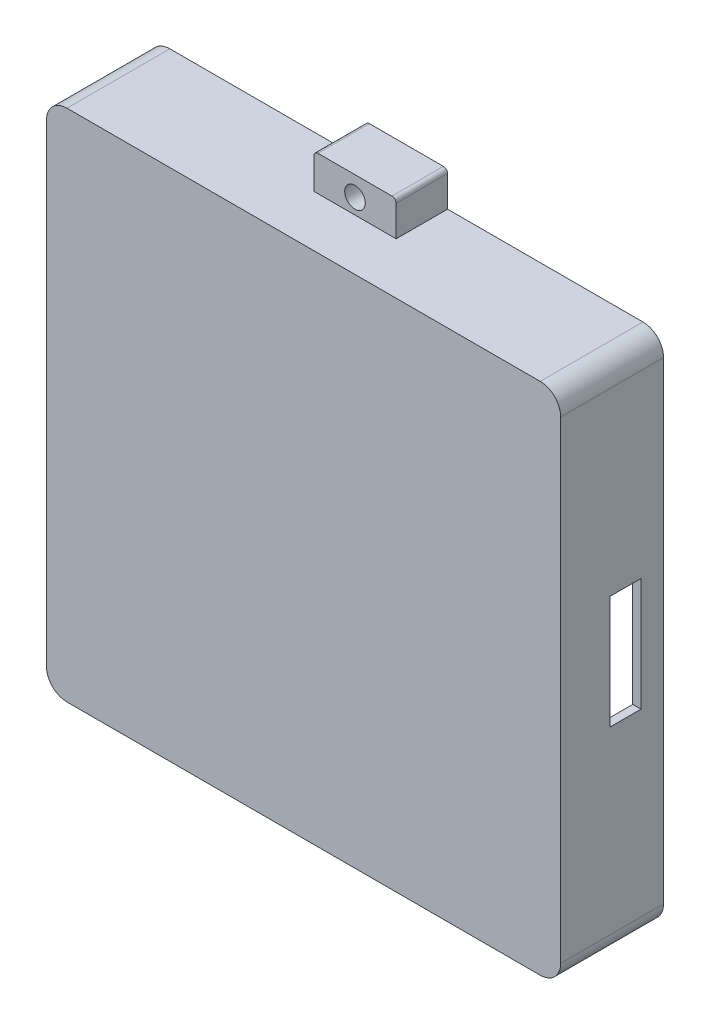
from build123d import *

# Parameters (mm, degrees)
SKETCH1_W           = 250
SKETCH1_H           = 250
BOSS_EXTRUDE1_DEPTH = 50
BOSS_EXTRUDE2_DEPTH = 25
SKETCH8_R           = 5
CUT_EXTRUDE1_DEPTH  = 25
SKETCH9_W           = 242
SKETCH9_H           = 242
CUT_EXTRUDE4_DEPTH  = 46
EXTRUDE_THIN2_DEPTH = 46
SKETCH15_R          = 11
CUT_EXTRUDE5_DEPTH  = 4
SKETCH17_W          = 15
SKETCH17_H          = 55
CUT_EXTRUDE7_DEPTH  = 4
SKETCH18_W          = 10
SKETCH18_H          = 16.5
CUT_EXTRUDE8_DEPTH  = 2.5
FILLET1_R           = 10
FILLET2_R           = 10


with BuildPart() as part:
    # Sketch1 → Boss-Extrude1 (new body)
    with BuildSketch(Plane.XY):
        with Locations((125, 125)):
            Rectangle(SKETCH1_W, SKETCH1_H)
    extrude(amount=BOSS_EXTRUDE1_DEPTH)

    # Sketch5 → Boss-Extrude2 (add)
    with BuildSketch(Plane.XY):
        with BuildLine():
            Line((105, 250), (105, 265))
            ThreePointArc((105, 265), (105.585786438, 266.414213562), (107, 267))
            Line((107, 267), (143, 267))
            ThreePointArc((143, 267), (144.414213562, 266.414213562), (145, 265))
            Line((145, 265), (145, 250))
            Line((145, 250), (105, 250))
        make_face()
    boss_extrude2 = extrude(amount=BOSS_EXTRUDE2_DEPTH)

    # Mirror1: Boss-Extrude2 across plane
    add(boss_extrude2.mirror(Plane.ZX.offset(125)))

    # Sketch8 → Cut-Extrude1 (cut)
    with BuildSketch(Plane(origin=(0, 0, 0), x_dir=(-1, 0, 0), z_dir=(0, 0, -1))):
        with Locations((-125, -7.5)):
            Circle(SKETCH8_R)
        with Locations((-125, 257.5)):
            Circle(SKETCH8_R)
    extrude(amount=-CUT_EXTRUDE1_DEPTH, mode=Mode.SUBTRACT)

    # Sketch9 → Cut-Extrude4 (cut)
    with BuildSketch(Plane(origin=(0, 0, 0), x_dir=(-1, 0, 0), z_dir=(0, 0, -1))):
        with Locations((-125, 125)):
            Rectangle(SKETCH9_W, SKETCH9_H)
    extrude(amount=-CUT_EXTRUDE4_DEPTH, mode=Mode.SUBTRACT)

    # Sketch14 → Extrude-Thin2 (add)
    with BuildSketch(Plane(origin=(0, 0, 0), x_dir=(-1, 0, 0), z_dir=(0, 0, -1))):
        Polygon((-4, 49), (-54, 49), (-54, 4), (-56.5, 4), (-56.5, 51.5), (-4, 51.5), align=None)
    extrude(amount=-EXTRUDE_THIN2_DEPTH)

    # Sketch15 → Cut-Extrude5 (cut)
    with BuildSketch(Plane.ZY):
        with Locations((26, 24)):
            Circle(SKETCH15_R)
    extrude(amount=-CUT_EXTRUDE5_DEPTH, mode=Mode.SUBTRACT)

    # Sketch17 → Cut-Extrude7 (cut)
    with BuildSketch(Plane(origin=(250, 0, 0), x_dir=(0, 0, -1), z_dir=(1, 0, 0))):
        with Locations((-18.5, 125)):
            Rectangle(SKETCH17_W, SKETCH17_H)
    extrude(amount=-CUT_EXTRUDE7_DEPTH, mode=Mode.SUBTRACT)

    # Sketch18 → Cut-Extrude8 (cut)
    with BuildSketch(Plane(origin=(0, 51.5, 0), x_dir=(1, 0, 0), z_dir=(0, 1, 0))):
        with Locations((40.5, -37.75)):
            Rectangle(SKETCH18_W, SKETCH18_H)
    extrude(amount=-CUT_EXTRUDE8_DEPTH, mode=Mode.SUBTRACT)

    # Fillet1
    fillet1_edges = [part.edges().sort_by_distance(p)[0] for p in [
        (0, 250, 25),
        (250, 250, 25),
        (250, 0, 25),
        (0, 0, 25),
    ]]
    fillet(fillet1_edges, radius=FILLET1_R)

    # Fillet2
    fillet2_edges = [part.edges().sort_by_distance(p)[0] for p in [
        (246, 246, 23),
        (4, 246, 23),
        (4, 4, 23),
        (246, 4, 23),
    ]]
    fillet(fillet2_edges, radius=FILLET2_R)


solid = part.part
